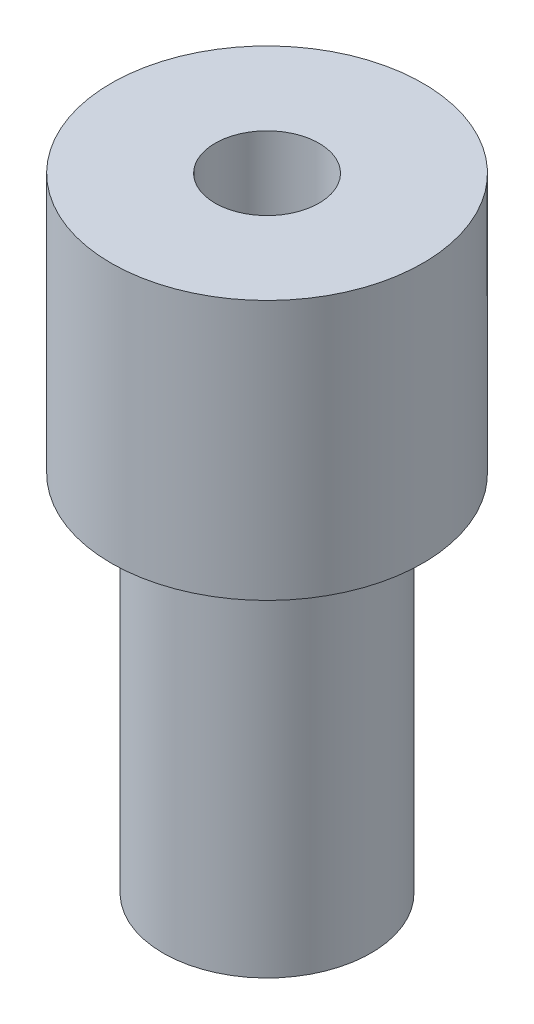
from build123d import *

# Parameters (mm, degrees)
SKETCH2_R           = 4
SKETCH2_R_2         = 2
BOSS_EXTRUDE1_DEPTH = 14
SKETCH3_R           = 6
SKETCH3_R_2         = 2
BOSS_EXTRUDE2_DEPTH = 10


with BuildPart() as part:
    # Sketch2 → Boss-Extrude1 (new body)
    with BuildSketch(Plane(origin=(0, 0, 0), x_dir=(1, 0, 0), z_dir=(0, 1, 0))):
        Circle(SKETCH2_R)
        Circle(SKETCH2_R_2, mode=Mode.SUBTRACT)
    extrude(amount=BOSS_EXTRUDE1_DEPTH)

    # Sketch3 → Boss-Extrude2 (add)
    with BuildSketch(Plane(origin=(0, 14, 0), x_dir=(1, 0, 0), z_dir=(0, 1, 0))):
        Circle(SKETCH3_R)
        Circle(SKETCH3_R_2, mode=Mode.SUBTRACT)
    extrude(amount=BOSS_EXTRUDE2_DEPTH)


solid = part.part
